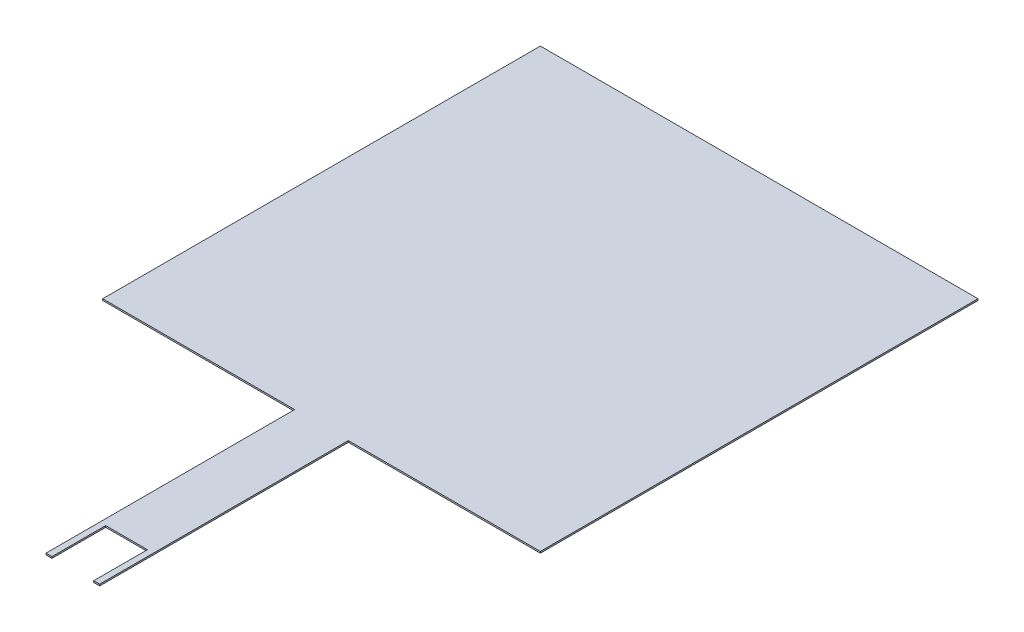
from build123d import *

# Parameters (mm, degrees)
BOSS_EXTRUDE1_DEPTH = 0.2032


with BuildPart() as part:
    # Sketch1 → Boss-Extrude1 (new body)
    with BuildSketch(Plane(origin=(0, 0, 0), x_dir=(1, 0, 0), z_dir=(0, 1, 0))):
        Polygon((3.429, -27.94), (27.94, -27.94), (27.94, 27.94), (-27.94, 27.94), (-27.94, -27.94), (-3.429, -27.94), (-3.429, -52.832), (-3.429, -59.69), (-2.667, -59.69), (-2.667, -52.832), (2.667, -52.832), (2.667, -59.69), (3.429, -59.69), (3.429, -52.832), align=None)
    extrude(amount=BOSS_EXTRUDE1_DEPTH)


solid = part.part
